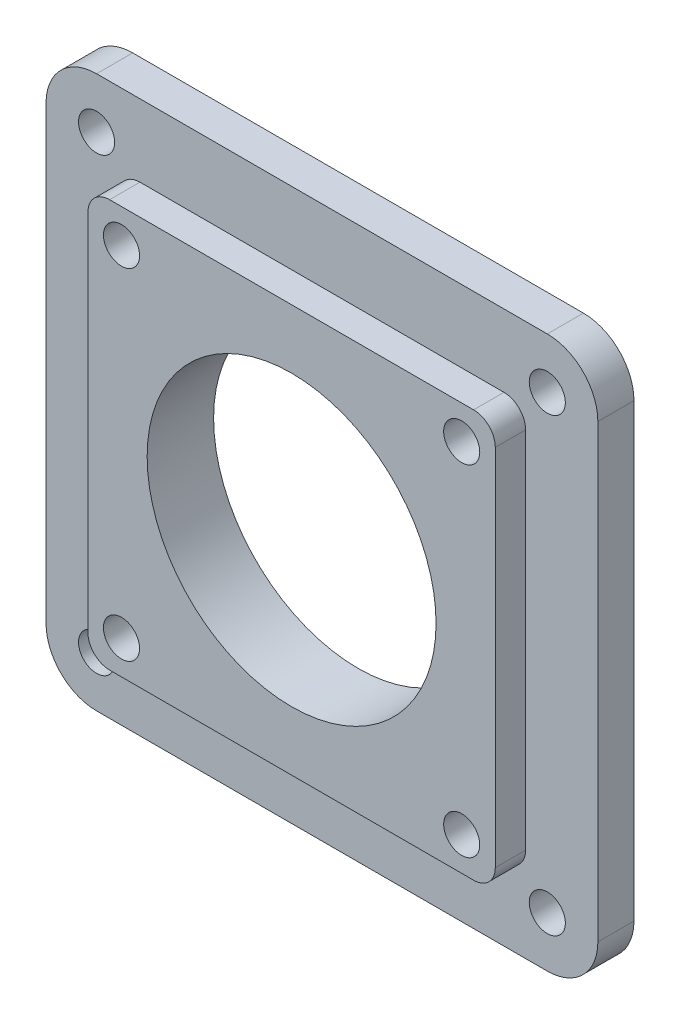
from build123d import *

# Parameters (mm, degrees)
SKETCH1_W               = 56.4
SKETCH1_H               = 56.4
BOSS_EXTRUDE1_DEPTH     = 4.2
SKETCH2_R               = 19.15
CUT_EXTRUDE1_DEPTH      = 1.6
SKETCH4_W               = 76.4
SKETCH4_H               = 76.4
BOSS_EXTRUDE2_DEPTH     = 5
SKETCH3_R               = 10
SKETCH3_R_2             = 2.5
CUT_EXTRUDE2_DEPTH      = 2.6
CUT_EXTRUDE2_DEPTH_BACK = 8.6
FILLET1_R               = 7
FILLET2_R               = 3
SKETCH5_R               = 2.5
CUT_EXTRUDE4_DEPTH      = 10
SKETCH6_R               = 20
CUT_EXTRUDE5_DEPTH      = 10


with BuildPart() as part:
    # Sketch1 → Boss-Extrude1 (new body)
    with BuildSketch(Plane.XY):
        Rectangle(SKETCH1_W, SKETCH1_H)
    extrude(amount=BOSS_EXTRUDE1_DEPTH)

    # Sketch2 → Cut-Extrude1 (cut)
    with BuildSketch(Plane.XY.offset(4.2)):
        Circle(SKETCH2_R)
    extrude(amount=-CUT_EXTRUDE1_DEPTH, mode=Mode.SUBTRACT)

    # Sketch4 → Boss-Extrude2 (add)
    with BuildSketch(Plane(origin=(0, 0, 0), x_dir=(-1, 0, 0), z_dir=(0, 0, -1))):
        Rectangle(SKETCH4_W, SKETCH4_H)
    extrude(amount=BOSS_EXTRUDE2_DEPTH)

    # Sketch3 → Cut-Extrude2 (cut, two sides)
    with BuildSketch(Plane.XY.offset(2.6)) as cut_extrude2_sk:
        Circle(SKETCH3_R)
        with Locations((23.55, -23.55)):
            Circle(SKETCH3_R_2)
        with Locations((-23.55, -23.55)):
            Circle(SKETCH3_R_2)
        with Locations((-23.55, 23.55)):
            Circle(SKETCH3_R_2)
        with Locations((23.55, 23.55)):
            Circle(SKETCH3_R_2)
    extrude(amount=CUT_EXTRUDE2_DEPTH, mode=Mode.SUBTRACT)
    extrude(cut_extrude2_sk.sketch, amount=-CUT_EXTRUDE2_DEPTH_BACK, mode=Mode.SUBTRACT)

    # Fillet1
    fillet1_edges = [part.edges().sort_by_distance(p)[0] for p in [
        (38.2, 38.2, -2.5),
        (38.2, -38.2, -2.5),
        (-38.2, -38.2, -2.5),
        (-38.2, 38.2, -2.5),
    ]]
    fillet(fillet1_edges, radius=FILLET1_R)

    # Fillet2
    fillet2_edges = [part.edges().sort_by_distance(p)[0] for p in [
        (28.2, -28.2, 2.1),
        (-28.2, -28.2, 2.1),
        (-28.2, 28.2, 2.1),
        (28.2, 28.2, 2.1),
    ]]
    fillet(fillet2_edges, radius=FILLET2_R)

    # Sketch5 → Cut-Extrude4 (cut)
    with BuildSketch(Plane(origin=(0, 0, -5), x_dir=(-1, 0, 0), z_dir=(0, 0, -1))):
        with Locations((-31.2, -31.2)):
            Circle(SKETCH5_R)
        with Locations((-31.2, 31.2)):
            Circle(SKETCH5_R)
        with Locations((31.2, 31.2)):
            Circle(SKETCH5_R)
        with Locations((31.2, -31.2)):
            Circle(SKETCH5_R)
    extrude(amount=-CUT_EXTRUDE4_DEPTH, mode=Mode.SUBTRACT)

    # Sketch6 → Cut-Extrude5 (cut)
    with BuildSketch(Plane(origin=(0, 0, -5), x_dir=(-1, 0, 0), z_dir=(0, 0, -1))):
        Circle(SKETCH6_R)
    extrude(amount=-CUT_EXTRUDE5_DEPTH, mode=Mode.SUBTRACT)


solid = part.part
